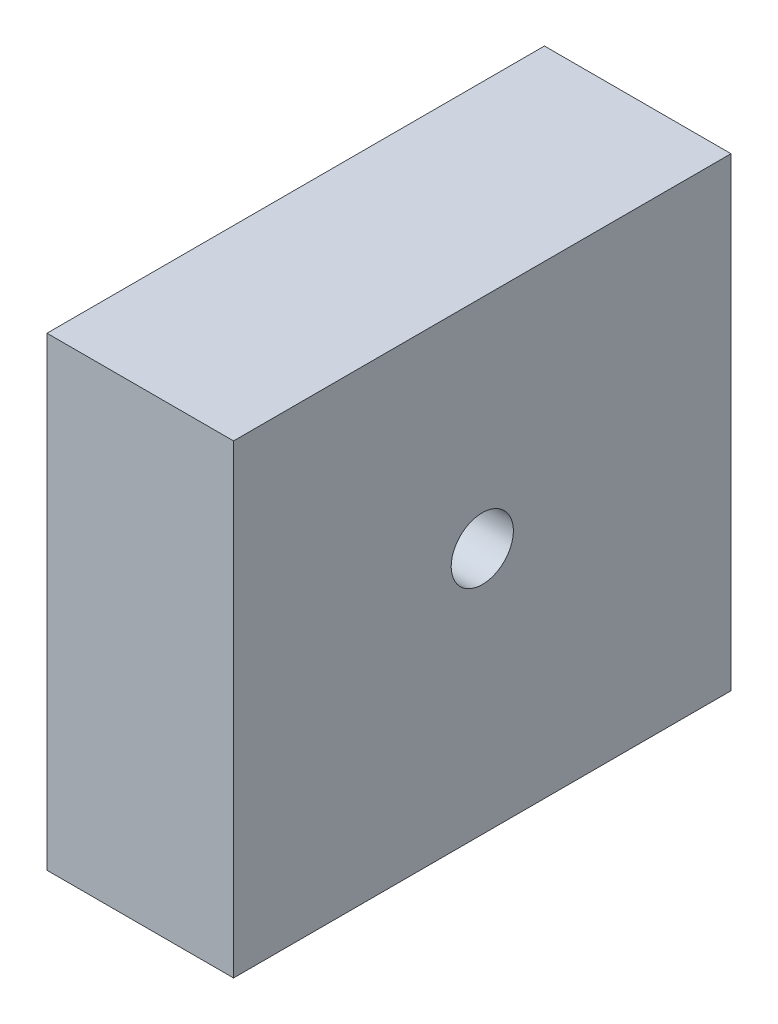
from build123d import *

# Parameters (mm, degrees)
SKETCH1_W                  = 19.05
SKETCH1_H                  = 50.8
BOSS_EXTRUDE1_DEPTH        = 47.498
F_1_4_0_2500_DOWEL_HOLE1_D = 6.35


with BuildPart() as part:
    # Sketch1 → Boss-Extrude1 (new body)
    with BuildSketch(Plane(origin=(0, 0, 0), x_dir=(1, 0, 0), z_dir=(0, 1, 0))):
        Rectangle(SKETCH1_W, SKETCH1_H)
    extrude(amount=BOSS_EXTRUDE1_DEPTH)

    # 1/4 (0.2500) Dowel Hole1 (through all)
    with Locations(Plane.ZY.offset(9.525)):
        with Locations((0, 25.273)):
            Hole(F_1_4_0_2500_DOWEL_HOLE1_D / 2)


solid = part.part
